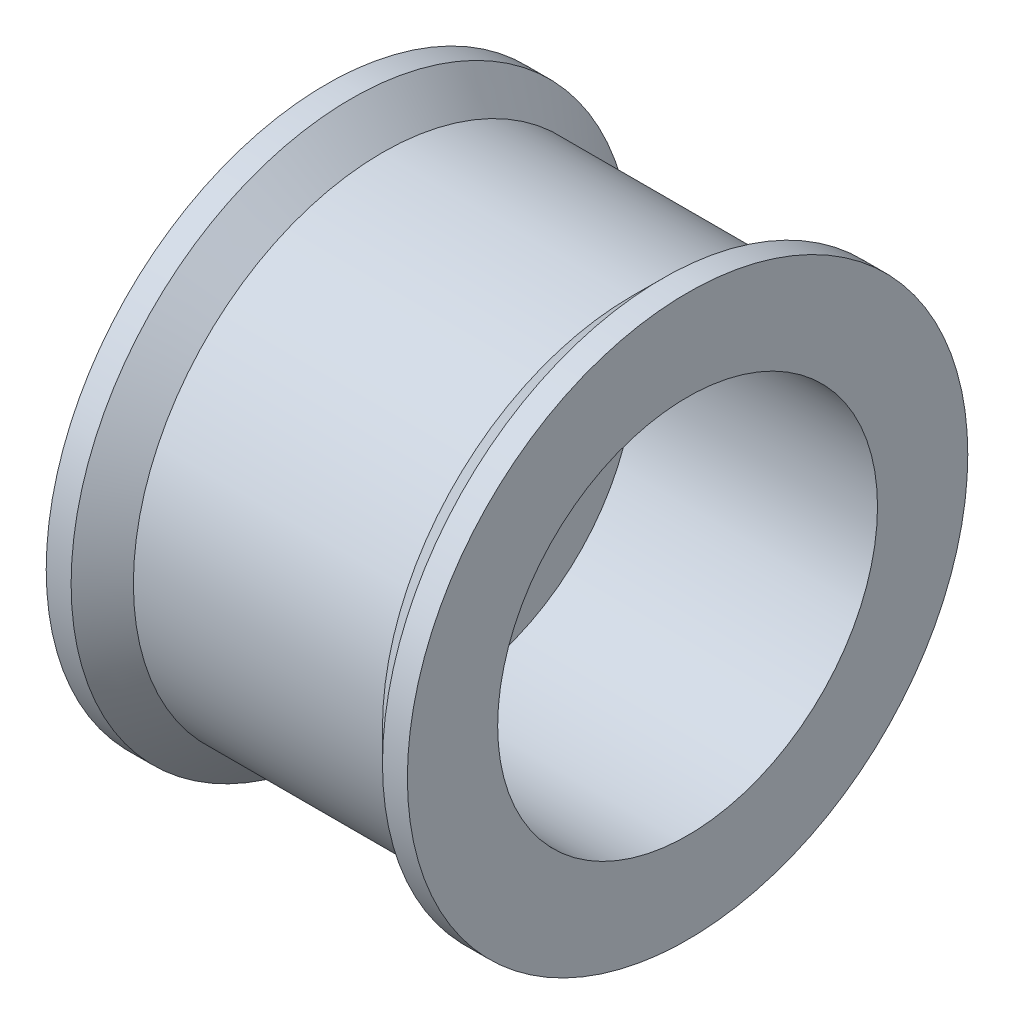
from build123d import *

# Parameters (mm, degrees)
SKETCH3_R               = 3.05
CUT_EXTRUDE1_DEPTH      = 10
CUT_EXTRUDE1_DEPTH_BACK = 1


with BuildPart() as part:
    # Sketch1 → Revolve1 (revolve)
    with BuildSketch(Plane.XY):
        Polygon((-2.9, 1.5), (-2.9, 4.5), (-2.5, 4.5), (-2, 4), (2, 4), (2.5, 4.5), (2.9, 4.5), (2.9, 1.5), align=None)
    revolve(axis=Axis((0, 0, 0), (1, 0, 0)))

    # Sketch3 → Cut-Extrude1 (cut, two sides)
    with BuildSketch(Plane(origin=(0, 0, 0), x_dir=(0, 0, -1), z_dir=(1, 0, 0))) as cut_extrude1_sk:
        Circle(SKETCH3_R)
    extrude(amount=CUT_EXTRUDE1_DEPTH, mode=Mode.SUBTRACT)
    extrude(cut_extrude1_sk.sketch, amount=-CUT_EXTRUDE1_DEPTH_BACK, mode=Mode.SUBTRACT)


solid = part.part
